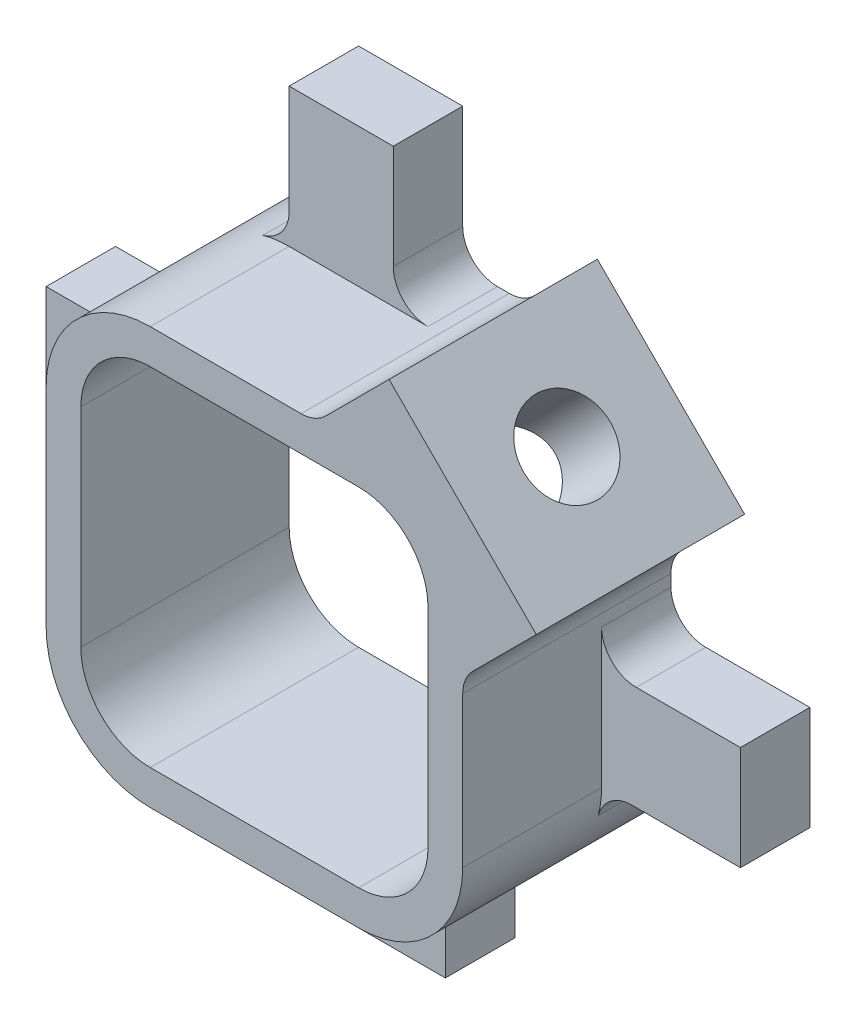
from build123d import *

# Parameters (mm, degrees)
SKIZZE1_W                       = 6
SKIZZE1_H                       = 6
SKIZZE1_W_2                     = 5
SKIZZE1_H_2                     = 5
AUFSATZ_LINEAR_AUSTRAGEN1_DEPTH = 3
VERRUNDUNG1_R                   = 1
SKIZZE2_W                       = 1.5
SKIZZE2_H                       = 2
SKIZZE2_W_2                     = 2
SKIZZE2_H_2                     = 1.5
AUFSATZ_LINEAR_AUSTRAGEN2_DEPTH = 1
VERRUNDUNG2_R                   = 1.5
VERRUNDUNG3_R                   = 0.5
M1_6_GEWINDEBOHRUNG5_D          = 1.25
M1_6_GEWINDEBOHRUNG5_DEPTH      = 3.09
M1_6_GEWINDEBOHRUNG5_TIP        = 0.625


with BuildPart() as part:
    # Skizze1 → Aufsatz-Linear austragen1 (new body)
    with BuildSketch(Plane.XY):
        Rectangle(SKIZZE1_W, SKIZZE1_H)
        Rectangle(SKIZZE1_W_2, SKIZZE1_H_2, mode=Mode.SUBTRACT)
        Polygon((1.939339828, 4.060660172), (0.878679656, 3), (3, 3), align=None)
        Polygon((4.060660172, 1.939339828), (3, 3), (3, 0.878679656), align=None)
    extrude(amount=AUFSATZ_LINEAR_AUSTRAGEN1_DEPTH)

    # Verrundung1
    verrundung1_edges = [part.edges().sort_by_distance(p)[0] for p in [
        (-2.5, 2.5, 1.5),
        (-2.5, -2.5, 1.5),
        (2.5, -2.5, 1.5),
        (2.5, 2.5, 1.5),
    ]]
    fillet(verrundung1_edges, radius=VERRUNDUNG1_R)

    # Skizze2 → Aufsatz-Linear austragen2 (add)
    with BuildSketch(Plane.XY):
        with Locations((-0.75, 4)):
            Rectangle(SKIZZE2_W, SKIZZE2_H)
        with Locations((0, -4)):
            Rectangle(SKIZZE2_W, SKIZZE2_H)
        with Locations((-4, 0)):
            Rectangle(SKIZZE2_W_2, SKIZZE2_H_2)
        with Locations((4, -0.75)):
            Rectangle(SKIZZE2_W_2, SKIZZE2_H_2)
    extrude(amount=AUFSATZ_LINEAR_AUSTRAGEN2_DEPTH)

    # Verrundung2
    verrundung2_edges = [part.edges().sort_by_distance(p)[0] for p in [
        (3, -3, 1.5),
        (-3, -3, 1.5),
        (-3, 3, 1.5),
    ]]
    fillet(verrundung2_edges, radius=VERRUNDUNG2_R)

    # Verrundung3
    verrundung3_edges = [part.edges().sort_by_distance(p)[0] for p in [
        (3, 0, 0.5),
        (3, -1.5, 0.5),
        (0.878679656, 3, 1.5),
        (3, 0.878679656, 1.5),
        (-1.5, 3, 0.5),
        (0, 3, 0.5),
        (0.75, -3, 0.5),
        (-0.75, -3, 0.5),
        (-3, -0.75, 0.5),
        (-3, 0.75, 0.5),
    ]]
    fillet(verrundung3_edges, radius=VERRUNDUNG3_R)

    # M1.6 Gewindebohrung5
    with Locations(Plane(origin=(3, 3, 0), x_dir=(0.707106781, -0.707106781, 0), z_dir=(0.707106781, 0.707106781, 0))):
        with Locations((0, -1.5)):
            Hole(M1_6_GEWINDEBOHRUNG5_D / 2, depth=M1_6_GEWINDEBOHRUNG5_DEPTH)
            with Locations((0, 0, -(M1_6_GEWINDEBOHRUNG5_DEPTH + M1_6_GEWINDEBOHRUNG5_TIP / 2))):  # 90° drill point
                Cone(0, M1_6_GEWINDEBOHRUNG5_D / 2, M1_6_GEWINDEBOHRUNG5_TIP, mode=Mode.SUBTRACT)


solid = part.part
